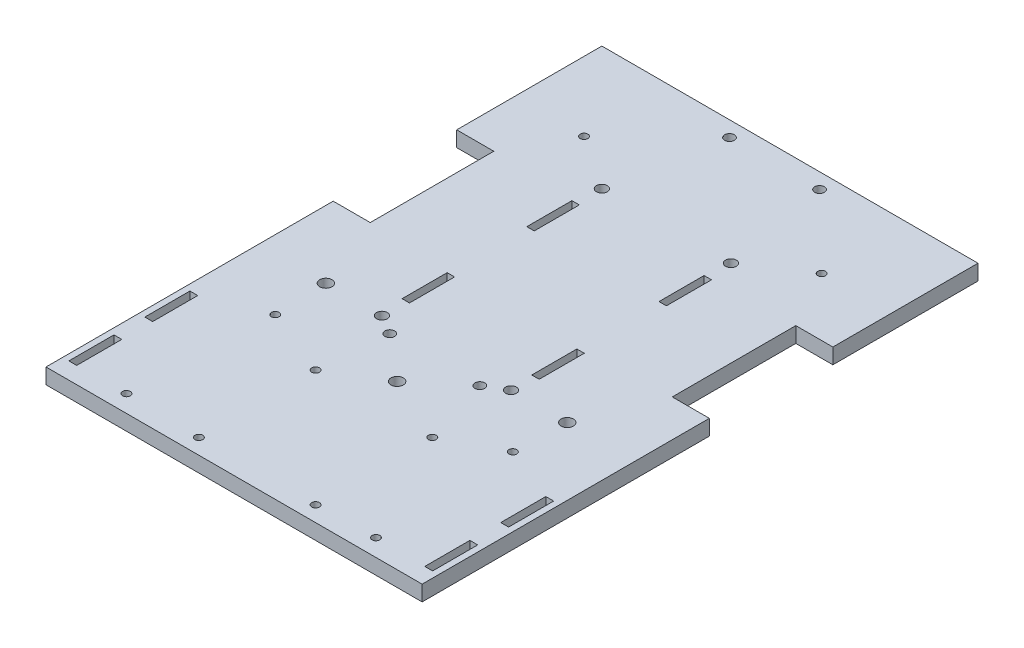
from build123d import *

# Parameters (mm, degrees)
SKETCH2_W           = 154.686
SKETCH2_H           = 228.6
BOSS_EXTRUDE1_DEPTH = 6.35
SKETCH1_R           = 2.2225
CUT_EXTRUDE1_DEPTH  = 6.35
SKETCH3_W           = 15.24
SKETCH3_H           = 50.8
CUT_EXTRUDE2_DEPTH  = 6.35
SKETCH8_R           = 2.54
CUT_EXTRUDE3_DEPTH  = 17.78
SKETCH9_R           = 1.5875
CUT_EXTRUDE4_DEPTH  = 17.78
SKETCH10_R          = 1.5875
CUT_EXTRUDE5_DEPTH  = 10.16
SKETCH12_W          = 3.048
SKETCH12_H          = 18.542
CUT_EXTRUDE7_DEPTH  = 8.255
SKETCH13_W          = 3.2258
SKETCH13_H          = 18.542
CUT_EXTRUDE8_DEPTH  = 7.35
SKETCH14_R          = 1.5875
CUT_EXTRUDE9_DEPTH  = 7.35
SKETCH16_R          = 2
CUT_EXTRUDE11_DEPTH = 7.35


with BuildPart() as part:
    # Sketch2 → Boss-Extrude1 (new body)
    with BuildSketch(Plane(origin=(0, 0, 0), x_dir=(1, 0, 0), z_dir=(0, 1, 0))):
        with Locations((26.543, 26.944051327)):
            Rectangle(SKETCH2_W, SKETCH2_H)
    extrude(amount=BOSS_EXTRUDE1_DEPTH)

    # Sketch1 → Cut-Extrude1 (cut)
    with BuildSketch(Plane(origin=(0, 0, 0), x_dir=(1, 0, 0), z_dir=(0, 1, 0))):
        with Locations((0, 90.444051327)):
            Circle(SKETCH1_R)
        with Locations((53.086, 90.444051327)):
            Circle(SKETCH1_R)
        Circle(SKETCH1_R)
        with Locations((53.086, 0)):
            Circle(SKETCH1_R)
    extrude(amount=CUT_EXTRUDE1_DEPTH, mode=Mode.SUBTRACT)

    # Sketch3 → Cut-Extrude2 (cut)
    with BuildSketch(Plane(origin=(0, 6.35, 0), x_dir=(1, 0, 0), z_dir=(0, 1, 0))):
        with Locations((96.266, 56.154051327)):
            Rectangle(SKETCH3_W, SKETCH3_H)
        with Locations((-43.18, 56.154051327)):
            Rectangle(SKETCH3_W, SKETCH3_H)
    extrude(amount=-CUT_EXTRUDE2_DEPTH, mode=Mode.SUBTRACT)

    # Sketch8 → Cut-Extrude3 (cut)
    with BuildSketch(Plane(origin=(0, 6.35, 0), x_dir=(1, 0, 0), z_dir=(0, 1, 0))):
        with Locations((26.550112, -20.29968)):
            Circle(SKETCH8_R)
        with Locations((-23.077082804, 0.02032)):
            Circle(SKETCH8_R)
        with Locations((76.177306804, 0.02032)):
            Circle(SKETCH8_R)
    extrude(amount=-CUT_EXTRUDE3_DEPTH, mode=Mode.SUBTRACT)

    # Sketch9 → Cut-Extrude4 (cut)
    with BuildSketch(Plane(origin=(0, 6.35, 0), x_dir=(1, 0, 0), z_dir=(0, 1, 0))):
        with Locations((53.722112, -33.005948673)):
            Circle(SKETCH9_R)
        with Locations((5.722112, -33.005948673)):
            Circle(SKETCH9_R)
        with Locations((53.722112, -81.005948673)):
            Circle(SKETCH9_R)
        with Locations((5.722112, -81.005948673)):
            Circle(SKETCH9_R)
    extrude(amount=-CUT_EXTRUDE4_DEPTH, mode=Mode.SUBTRACT)

    # Sketch10 → Cut-Extrude5 (cut)
    with BuildSketch(Plane(origin=(0, 6.35, 0), x_dir=(1, 0, 0), z_dir=(0, 1, 0))):
        with Locations((-22.3266, 105.430051327)):
            Circle(SKETCH10_R)
        with Locations((-22.3266, -21.569948673)):
            Circle(SKETCH10_R)
        with Locations((75.4126, 105.430051327)):
            Circle(SKETCH10_R)
        with Locations((75.4126, -21.569948673)):
            Circle(SKETCH10_R)
    extrude(amount=-CUT_EXTRUDE5_DEPTH, mode=Mode.SUBTRACT)

    # Sketch12 → Cut-Extrude7 (cut)
    with BuildSketch(Plane(origin=(0, 6.35, 0), x_dir=(1, 0, 0), z_dir=(0, 1, 0))):
        with Locations((-0.373888, 19.451051327)):
            Rectangle(SKETCH12_W, SKETCH12_H)
        with Locations((-0.373888, 70.759051327)):
            Rectangle(SKETCH12_W, SKETCH12_H)
        with Locations((53.474112, 71.267051327)):
            Rectangle(SKETCH12_W, SKETCH12_H)
        with Locations((53.474112, 18.943051327)):
            Rectangle(SKETCH12_W, SKETCH12_H)
    extrude(amount=-CUT_EXTRUDE7_DEPTH, mode=Mode.SUBTRACT)

    # Sketch13 → Cut-Extrude8 (cut, through all)
    with BuildSketch(Plane(origin=(0, 6.35, 0), x_dir=(1, 0, 0), z_dir=(0, 1, 0))):
        with Locations((-46.6471, -39.984948673)):
            Rectangle(SKETCH13_W, SKETCH13_H)
        with Locations((-46.6471, -71.226948673)):
            Rectangle(SKETCH13_W, SKETCH13_H)
        with Locations((99.7331, -71.226948673)):
            Rectangle(SKETCH13_W, SKETCH13_H)
        with Locations((99.7331, -39.984948673)):
            Rectangle(SKETCH13_W, SKETCH13_H)
    extrude(amount=-CUT_EXTRUDE8_DEPTH, mode=Mode.SUBTRACT)

    # Sketch14 → Cut-Extrude9 (cut, through all)
    with BuildSketch(Plane(origin=(0, 6.35, 0), x_dir=(1, 0, 0), z_dir=(0, 1, 0))):
        with Locations((-24.765, -80.309322307)):
            Circle(SKETCH14_R)
        with Locations((77.851, -80.309322307)):
            Circle(SKETCH14_R)
    extrude(amount=-CUT_EXTRUDE9_DEPTH, mode=Mode.SUBTRACT)

    # Sketch16 → Cut-Extrude11 (cut, through all)
    with BuildSketch(Plane(origin=(0, 6.35, 0), x_dir=(1, 0, 0), z_dir=(0, 1, 0))):
        with Locations((45.060116, 134.894051327)):
            Circle(SKETCH16_R)
        with Locations((8.040116, 134.894051327)):
            Circle(SKETCH16_R)
        with Locations((8.040116, -4.805948673)):
            Circle(SKETCH16_R)
        with Locations((45.060116, -4.805948673)):
            Circle(SKETCH16_R)
    extrude(amount=-CUT_EXTRUDE11_DEPTH, mode=Mode.SUBTRACT)


solid = part.part
